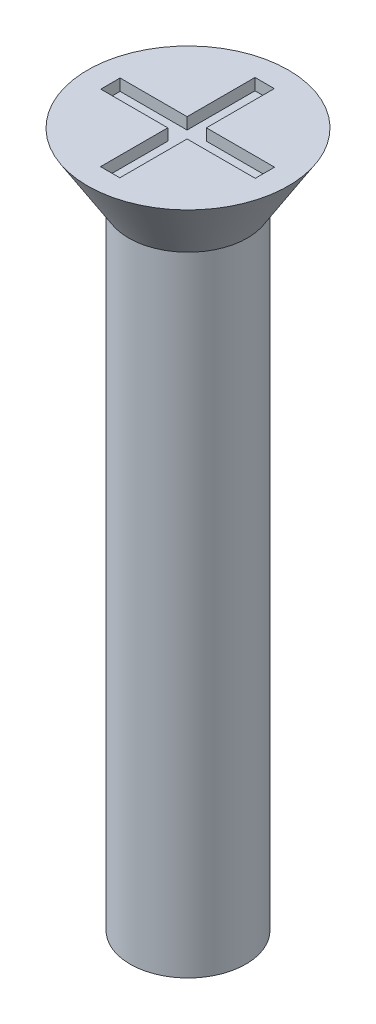
from build123d import *

# Parameters (mm, degrees)
SKETCH1_R           = 1.5
BOSS_EXTRUDE1_DEPTH = 18
SKETCH2_R           = 2.6
BOSS_EXTRUDE2_DEPTH = 1.7
BOSS_EXTRUDE2_TAPER = 32
SKETCH3_W           = 0.5
SKETCH3_H           = 1.758378485
SKETCH3_H_2         = 1.741621515
SKETCH3_W_2         = 1.734727157
SKETCH3_H_3         = 0.5
SKETCH3_W_3         = 1.765272843
CUT_EXTRUDE1_DEPTH  = 0.3


with BuildPart() as part:
    # Sketch1 → Boss-Extrude1 (new body)
    with BuildSketch(Plane(origin=(0, 0, 0), x_dir=(1, 0, 0), z_dir=(0, 1, 0))):
        Circle(SKETCH1_R)
    extrude(amount=BOSS_EXTRUDE1_DEPTH)

    # Sketch2 → Boss-Extrude2 (add)
    with BuildSketch(Plane(origin=(0, 18, 0), x_dir=(1, 0, 0), z_dir=(0, 1, 0))):
        Circle(SKETCH2_R)
    extrude(amount=-BOSS_EXTRUDE2_DEPTH, taper=BOSS_EXTRUDE2_TAPER)

    # Sketch3 → Cut-Extrude1 (cut)
    with BuildSketch(Plane(origin=(0, 18, 0), x_dir=(1, 0, 0), z_dir=(0, 1, 0))):
        with Locations((-0.015272843, 1.120810757)):
            Rectangle(SKETCH3_W, SKETCH3_H)
        with Locations((-0.015272843, -1.129189243)):
            Rectangle(SKETCH3_W, SKETCH3_H_2)
        with Locations((-1.132636421, -0.008378485)):
            Rectangle(SKETCH3_W_2, SKETCH3_H_3)
        with Locations((1.117363579, -0.008378485)):
            Rectangle(SKETCH3_W_3, SKETCH3_H_3)
        with Locations((-0.015272843, -0.008378485)):
            Rectangle(SKETCH3_W, SKETCH3_H_3)
    extrude(amount=-CUT_EXTRUDE1_DEPTH, mode=Mode.SUBTRACT)


solid = part.part
